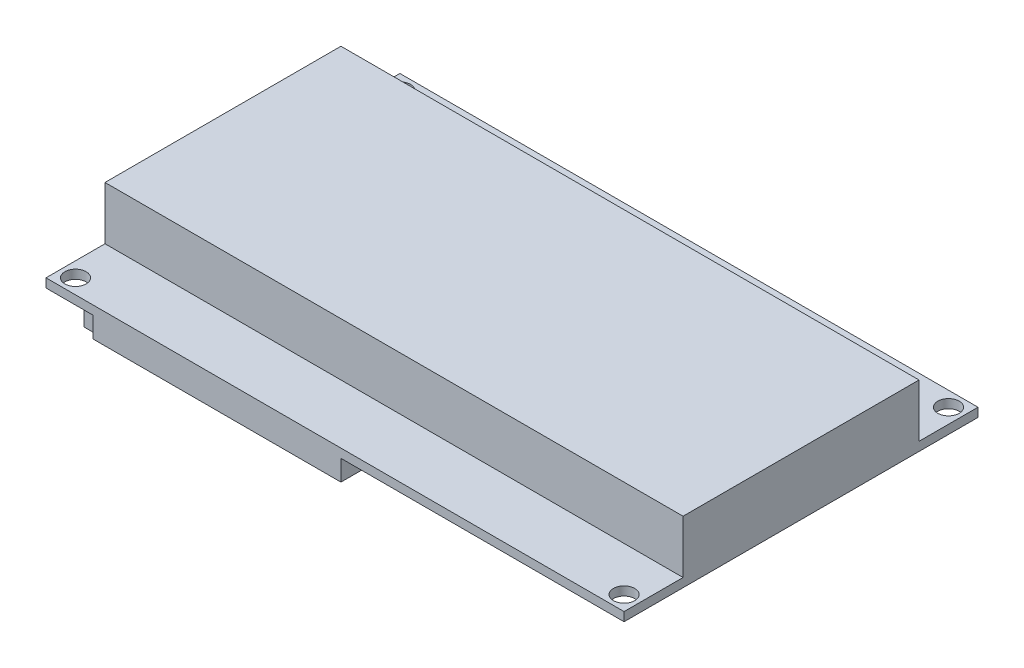
from build123d import *

# Parameters (mm, degrees)
SKIZZE1_W                            = 49
SKIZZE1_H                            = 30
AUFSATZ_LINEAR_AUSTRAGEN1_DEPTH      = 1.5
SKIZZE2_W                            = 49
SKIZZE2_H                            = 20
AUFSATZ_LINEAR_AUSTRAGEN2_DEPTH      = 9
SKIZZE3_R                            = 1.8
SCHNITT_LINEAR_AUSTRAGEN1_DEPTH      = 10
SCHNITT_LINEAR_AUSTRAGEN1_DEPTH_BACK = 2.5
SKIZZE4_W                            = 42
SKIZZE4_H                            = 20.4
AUFSATZ_LINEAR_AUSTRAGEN3_DEPTH      = 3.5
SKIZZE5_W                            = 9.3
SKIZZE5_H                            = 10
SKIZZE5_W_2                          = 5.202111929
SKIZZE5_H_2                          = 5.340958118
SKIZZE5_W_3                          = 5.892281305
SKIZZE5_H_3                          = 9.90280044
SKIZZE5_H_4                          = 4.8
AUFSATZ_LINEAR_AUSTRAGEN4_DEPTH      = 4.2


with BuildPart() as part:
    # Skizze1 → Aufsatz-Linear austragen1 (new body)
    with BuildSketch(Plane(origin=(0, 0, 0), x_dir=(1, 0, 0), z_dir=(0, 1, 0))):
        with Locations((-24.5, -15)):
            Rectangle(SKIZZE1_W, SKIZZE1_H)
    extrude(amount=AUFSATZ_LINEAR_AUSTRAGEN1_DEPTH)

    # Skizze2 → Aufsatz-Linear austragen2 (add)
    with BuildSketch(Plane(origin=(0, 1.5, 0), x_dir=(1, 0, 0), z_dir=(0, 1, 0))):
        with Locations((-24.5, -10)):
            Rectangle(SKIZZE2_W, SKIZZE2_H)
    extrude(amount=AUFSATZ_LINEAR_AUSTRAGEN2_DEPTH)

    # Skizze3 → Schnitt-Linear austragen1 (cut, two sides)
    with BuildSketch(Plane(origin=(0, 1.5, 0), x_dir=(1, 0, 0), z_dir=(0, 1, 0))) as schnitt_linear_austragen1_sk:
        with Locations((-46.5, -27.5)):
            Circle(SKIZZE3_R)
    extrude(amount=SCHNITT_LINEAR_AUSTRAGEN1_DEPTH, mode=Mode.SUBTRACT)
    extrude(schnitt_linear_austragen1_sk.sketch, amount=-SCHNITT_LINEAR_AUSTRAGEN1_DEPTH_BACK, mode=Mode.SUBTRACT)

    # Spiegeln1: part across plane


with BuildPart() as part_1:
    add(part.part)
    add(part.part.mirror(Plane(origin=(0, 1.5, 0), x_dir=(0, 0, 1), z_dir=(-1, 0, 0))))

    # Spiegeln2: part across plane


with BuildPart() as part_2:
    add(part_1.part)
    add(part_1.part.mirror(Plane(origin=(0, 1.5, 0), x_dir=(1, 0, 0), z_dir=(0, 0, 1))))

    # Skizze4 → Aufsatz-Linear austragen3 (add)
    with BuildSketch(Plane.XZ):
        with Locations((-20, 19.8)):
            Rectangle(SKIZZE4_W, SKIZZE4_H)
    extrude(amount=AUFSATZ_LINEAR_AUSTRAGEN3_DEPTH)

    # Skizze5 → Aufsatz-Linear austragen4 (add)
    with BuildSketch(Plane.XZ.offset(3.5)):
        with Locations((-43.15, 19.8)):
            Rectangle(SKIZZE5_W, SKIZZE5_H)
        with Locations((-28.561234427, 15.050145035)):
            Rectangle(SKIZZE5_W_2, SKIZZE5_H_2)
        with Locations((-17.866219882, 19.8)):
            Rectangle(SKIZZE5_W_3, SKIZZE5_H_3)
        with Locations((3.15, 17.4)):
            Rectangle(SKIZZE5_W, SKIZZE5_H_4)
    extrude(amount=AUFSATZ_LINEAR_AUSTRAGEN4_DEPTH)


solid = part_2.part
